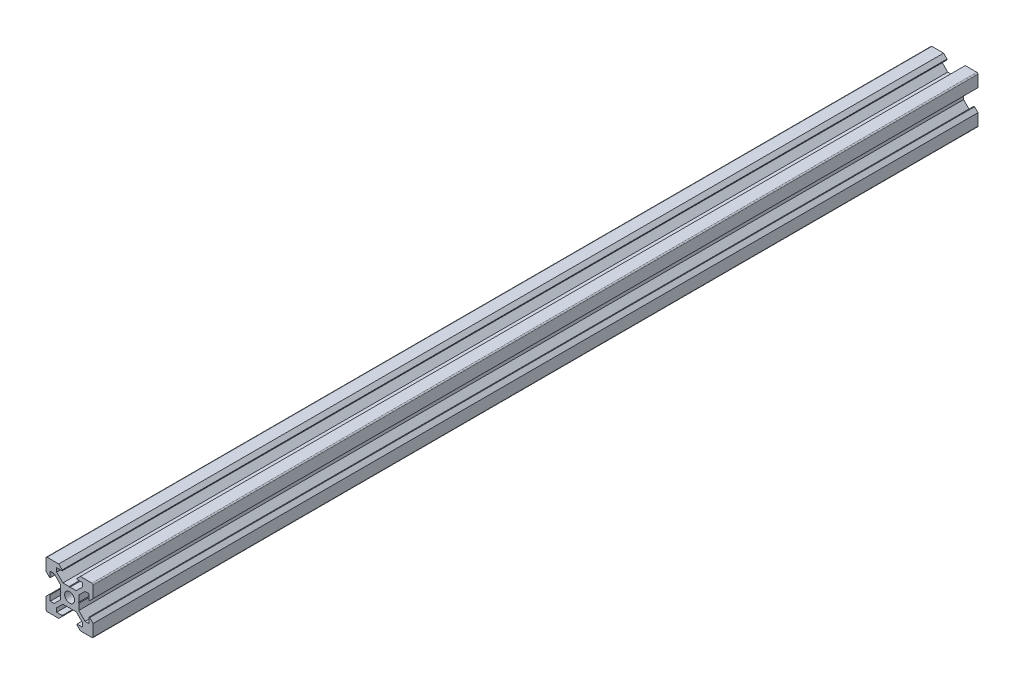
from build123d import *

# Parameters (mm, degrees)
SKETCH1_R           = 2.1
BOSS_EXTRUDE1_DEPTH = 187.57


with BuildPart() as part:
    # Sketch1 → Boss-Extrude1 (new body, symmetric)
    with BuildSketch(Plane.XY):
        with BuildLine():
            Line((4.58, -10), (9.5, -10))
            ThreePointArc((9.5, -10), (9.853553391, -9.853553391), (10, -9.5))
            Line((10, -9.5), (10, -4.58))
            Line((10, -4.58), (8.545, -3.125))
            Line((8.545, -3.125), (8.2, -3.125))
            Line((8.2, -3.125), (8.2, -5.5))
            Line((8.2, -5.5), (6.560660172, -5.5))
            Line((6.560660172, -5.5), (3.9, -2.839339828))
            Line((3.9, -2.839339828), (3.9, -0.21))
            Line((3.9, -0.21), (3.69, 0))
            Line((3.69, 0), (3.9, 0.21))
            Line((3.9, 0.21), (3.9, 2.839339828))
            Line((3.9, 2.839339828), (6.560660172, 5.5))
            Line((6.560660172, 5.5), (8.2, 5.5))
            Line((8.2, 5.5), (8.2, 3.125))
            Line((8.2, 3.125), (8.545, 3.125))
            Line((8.545, 3.125), (10, 4.58))
            Line((10, 4.58), (10, 9.5))
            ThreePointArc((10, 9.5), (9.853553391, 9.853553391), (9.5, 10))
            Line((9.5, 10), (4.58, 10))
            Line((4.58, 10), (3.125, 8.545))
            Line((3.125, 8.545), (3.125, 8.2))
            Line((3.125, 8.2), (5.5, 8.2))
            Line((5.5, 8.2), (5.5, 6.560660172))
            Line((5.5, 6.560660172), (2.839339828, 3.9))
            Line((2.839339828, 3.9), (0.21, 3.9))
            Line((0.21, 3.9), (0, 3.69))
            Line((0, 3.69), (-0.21, 3.9))
            Line((-0.21, 3.9), (-2.839339828, 3.9))
            Line((-2.839339828, 3.9), (-5.5, 6.560660172))
            Line((-5.5, 6.560660172), (-5.5, 8.2))
            Line((-5.5, 8.2), (-3.125, 8.2))
            Line((-3.125, 8.2), (-3.125, 8.545))
            Line((-3.125, 8.545), (-4.58, 10))
            Line((-4.58, 10), (-9.5, 10))
            ThreePointArc((-9.5, 10), (-9.853553391, 9.853553391), (-10, 9.5))
            Line((-10, 9.5), (-10, 4.58))
            Line((-10, 4.58), (-8.545, 3.125))
            Line((-8.545, 3.125), (-8.2, 3.125))
            Line((-8.2, 3.125), (-8.2, 5.5))
            Line((-8.2, 5.5), (-6.560660172, 5.5))
            Line((-6.560660172, 5.5), (-3.9, 2.839339828))
            Line((-3.9, 2.839339828), (-3.9, 0.21))
            Line((-3.9, 0.21), (-3.69, 0))
            Line((-3.69, 0), (-3.9, -0.21))
            Line((-3.9, -0.21), (-3.9, -2.839339828))
            Line((-3.9, -2.839339828), (-6.560660172, -5.5))
            Line((-6.560660172, -5.5), (-8.2, -5.5))
            Line((-8.2, -5.5), (-8.2, -3.125))
            Line((-8.2, -3.125), (-8.545, -3.125))
            Line((-8.545, -3.125), (-10, -4.58))
            Line((-10, -4.58), (-10, -9.5))
            ThreePointArc((-10, -9.5), (-9.853553391, -9.853553391), (-9.5, -10))
            Line((-9.5, -10), (-4.58, -10))
            Line((-4.58, -10), (-3.125, -8.545))
            Line((-3.125, -8.545), (-3.125, -8.2))
            Line((-3.125, -8.2), (-5.5, -8.2))
            Line((-5.5, -8.2), (-5.5, -6.560660172))
            Line((-5.5, -6.560660172), (-2.839339828, -3.9))
            Line((-2.839339828, -3.9), (-0.21, -3.9))
            Line((-0.21, -3.9), (0, -3.69))
            Line((0, -3.69), (0.21, -3.9))
            Line((0.21, -3.9), (2.839339828, -3.9))
            Line((2.839339828, -3.9), (5.5, -6.560660172))
            Line((5.5, -6.560660172), (5.5, -8.2))
            Line((5.5, -8.2), (3.125, -8.2))
            Line((3.125, -8.2), (3.125, -8.545))
            Line((3.125, -8.545), (4.58, -10))
        make_face()
        Circle(SKETCH1_R, mode=Mode.SUBTRACT)
    extrude(amount=BOSS_EXTRUDE1_DEPTH, both=True)


solid = part.part
